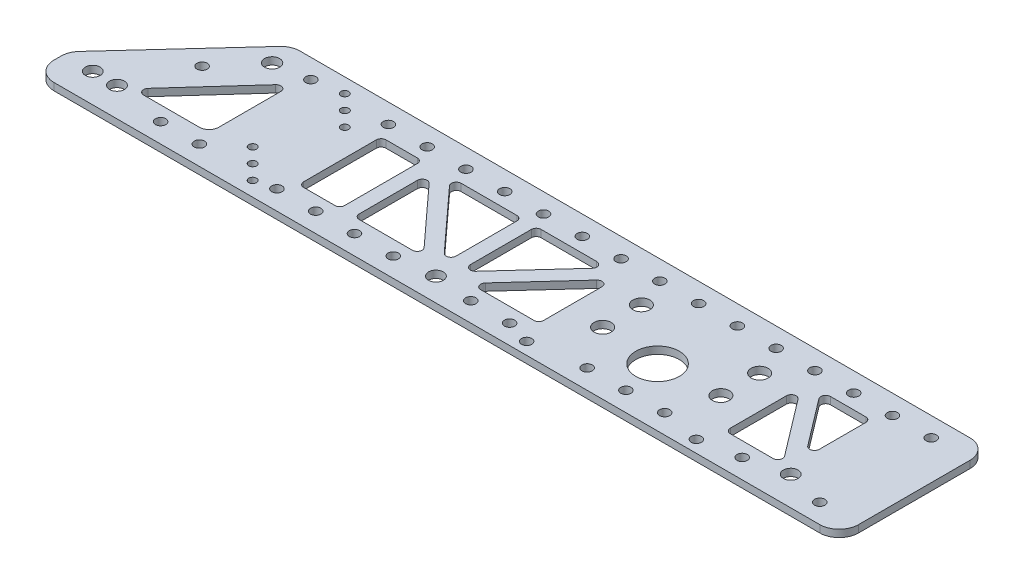
from build123d import *

# Parameters (mm, degrees)
SKETCH1_R           = 4.826
SKETCH1_R_2         = 14.28115
SKETCH1_R_3         = 3.3528
SKETCH1_R_4         = 4.953
SKETCH1_R_5         = 3.3782
SKETCH1_R_6         = 2.5527
SKETCH1_R_7         = 5.5626
BOSS_EXTRUDE1_DEPTH = 4.7625


with BuildPart() as part:
    # Sketch1 → Boss-Extrude1 (new body)
    with BuildSketch(Plane.XZ):
        with BuildLine():
            Line((3.338142419, -25.866609912), (66.074894217, -94.306702782))
            ThreePointArc((66.074894217, -94.306702782), (70.322928635, -97.34992205), (75.436751798, -98.425))
            Line((75.436751798, -98.425), (514.35, -98.425))
            ThreePointArc((514.35, -98.425), (523.330256121, -94.705256121), (527.05, -85.725))
            Line((527.05, -85.725), (527.05, -12.7))
            ThreePointArc((527.05, -12.7), (523.330256121, -3.719743879), (514.35, 0))
            Line((514.35, 0), (12.7, 0))
            ThreePointArc((12.7, 0), (3.719743879, -3.719743879), (0, -12.7))
            Line((0, -12.7), (0, -17.28490713))
            ThreePointArc((0, -17.28490713), (0.863919752, -21.888949307), (3.338142419, -25.866609912))
        make_face()
        with Locations((34.925, -19.05)):
            Circle(SKETCH1_R, mode=Mode.SUBTRACT)
        with Locations((476.25, -19.05)):
            Circle(SKETCH1_R, mode=Mode.SUBTRACT)
        with Locations((19.05, -19.05)):
            Circle(SKETCH1_R, mode=Mode.SUBTRACT)
        with Locations((247.65, -15.24)):
            Circle(SKETCH1_R, mode=Mode.SUBTRACT)
        with Locations((369.99417663, -38.1)):
            Circle(SKETCH1_R_2, mode=Mode.SUBTRACT)
        with Locations((314.41897663, -7.9248)):
            Circle(SKETCH1_R_3, mode=Mode.SUBTRACT)
        with Locations((425.56937663, -7.9248)):
            Circle(SKETCH1_R_3, mode=Mode.SUBTRACT)
        with Locations((73.025, -82.55)):
            Circle(SKETCH1_R_4, mode=Mode.SUBTRACT)
        with Locations((95.25, -12.7)):
            Circle(SKETCH1_R_5, mode=Mode.SUBTRACT)
        with Locations((95.25, -85.725)):
            Circle(SKETCH1_R_5, mode=Mode.SUBTRACT)
        with Locations((146.05, -12.7)):
            Circle(SKETCH1_R_5, mode=Mode.SUBTRACT)
        with Locations((146.05, -85.725)):
            Circle(SKETCH1_R_5, mode=Mode.SUBTRACT)
        with Locations((171.45, -12.7)):
            Circle(SKETCH1_R_5, mode=Mode.SUBTRACT)
        with Locations((171.45, -85.725)):
            Circle(SKETCH1_R_5, mode=Mode.SUBTRACT)
        with Locations((196.85, -12.7)):
            Circle(SKETCH1_R_5, mode=Mode.SUBTRACT)
        with Locations((196.85, -85.725)):
            Circle(SKETCH1_R_5, mode=Mode.SUBTRACT)
        with Locations((222.25, -12.7)):
            Circle(SKETCH1_R_5, mode=Mode.SUBTRACT)
        with Locations((222.25, -85.725)):
            Circle(SKETCH1_R_5, mode=Mode.SUBTRACT)
        with Locations((247.65, -85.725)):
            Circle(SKETCH1_R_5, mode=Mode.SUBTRACT)
        with Locations((273.05, -12.7)):
            Circle(SKETCH1_R_5, mode=Mode.SUBTRACT)
        with Locations((273.05, -85.725)):
            Circle(SKETCH1_R_5, mode=Mode.SUBTRACT)
        with Locations((298.45, -12.7)):
            Circle(SKETCH1_R_5, mode=Mode.SUBTRACT)
        with Locations((298.45, -85.725)):
            Circle(SKETCH1_R_5, mode=Mode.SUBTRACT)
        with Locations((323.85, -85.725)):
            Circle(SKETCH1_R_5, mode=Mode.SUBTRACT)
        with Locations((349.25, -12.7)):
            Circle(SKETCH1_R_5, mode=Mode.SUBTRACT)
        with Locations((349.25, -85.725)):
            Circle(SKETCH1_R_5, mode=Mode.SUBTRACT)
        with Locations((374.65, -12.7)):
            Circle(SKETCH1_R_5, mode=Mode.SUBTRACT)
        with Locations((374.65, -85.725)):
            Circle(SKETCH1_R_5, mode=Mode.SUBTRACT)
        with Locations((400.05, -12.7)):
            Circle(SKETCH1_R_5, mode=Mode.SUBTRACT)
        with Locations((400.05, -85.725)):
            Circle(SKETCH1_R_5, mode=Mode.SUBTRACT)
        with Locations((425.45, -85.725)):
            Circle(SKETCH1_R_5, mode=Mode.SUBTRACT)
        with Locations((450.85, -12.7)):
            Circle(SKETCH1_R_5, mode=Mode.SUBTRACT)
        with Locations((450.85, -85.725)):
            Circle(SKETCH1_R_5, mode=Mode.SUBTRACT)
        with Locations((476.25, -85.725)):
            Circle(SKETCH1_R_5, mode=Mode.SUBTRACT)
        with Locations((501.65, -12.7)):
            Circle(SKETCH1_R_5, mode=Mode.SUBTRACT)
        with Locations((501.65, -85.725)):
            Circle(SKETCH1_R_5, mode=Mode.SUBTRACT)
        with Locations((123.825, -19.05)):
            Circle(SKETCH1_R_6, mode=Mode.SUBTRACT)
        with Locations((114.3, -28.575)):
            Circle(SKETCH1_R_6, mode=Mode.SUBTRACT)
        with Locations((133.35, -9.525)):
            Circle(SKETCH1_R_6, mode=Mode.SUBTRACT)
        with Locations((114.3, -88.9)):
            Circle(SKETCH1_R_6, mode=Mode.SUBTRACT)
        with Locations((123.825, -79.375)):
            Circle(SKETCH1_R_6, mode=Mode.SUBTRACT)
        with Locations((133.35, -69.85)):
            Circle(SKETCH1_R_6, mode=Mode.SUBTRACT)
        with Locations((331.25917663, -40.8178)):
            Circle(SKETCH1_R_7, mode=Mode.SUBTRACT)
        with Locations((408.72917663, -66.2178)):
            Circle(SKETCH1_R_7, mode=Mode.SUBTRACT)
        with Locations((331.25917663, -66.2178)):
            Circle(SKETCH1_R_7, mode=Mode.SUBTRACT)
        with Locations((408.72917663, -40.8178)):
            Circle(SKETCH1_R_7, mode=Mode.SUBTRACT)
        with Locations((69.85, -12.7)):
            Circle(SKETCH1_R_5, mode=Mode.SUBTRACT)
        with Locations((51.950539741, -57.756517342)):
            Circle(SKETCH1_R_5, mode=Mode.SUBTRACT)
        with BuildLine():
            Line((49.23354708, -22.225), (85.725, -22.225))
            ThreePointArc((85.725, -22.225), (90.215128061, -24.084871939), (92.075, -28.575))
            Line((92.075, -28.575), (92.075, -69.241869017))
            ThreePointArc((92.075, -69.241869017), (90.041376556, -72.204618509), (86.545623901, -71.37201882))
            Line((86.545623901, -71.37201882), (46.879170981, -27.530149804))
            ThreePointArc((46.879170981, -27.530149804), (46.33149172, -24.112094846), (49.23354708, -22.225))
        make_face(mode=Mode.SUBTRACT)
        with BuildLine():
            Line((174.53102337, -76.2), (153.9875, -76.2))
            ThreePointArc((153.9875, -76.2), (151.74243597, -75.27006403), (150.8125, -73.025))
            Line((150.8125, -73.025), (150.8125, -25.4))
            ThreePointArc((150.8125, -25.4), (151.74243597, -23.15493597), (153.9875, -22.225))
            Line((153.9875, -22.225), (174.53102337, -22.225))
            ThreePointArc((174.53102337, -22.225), (176.7760874, -23.15493597), (177.70602337, -25.4))
            Line((177.70602337, -25.4), (177.70602337, -73.025))
            ThreePointArc((177.70602337, -73.025), (176.7760874, -75.27006403), (174.53102337, -76.2))
        make_face(mode=Mode.SUBTRACT)
        with BuildLine():
            Line((227.625953961, -27.542449226), (192.749212716, -65.68702112))
            ThreePointArc((192.749212716, -65.68702112), (189.25689352, -66.504322828), (187.23102337, -63.544571894))
            Line((187.23102337, -63.544571894), (187.23102337, -25.4))
            ThreePointArc((187.23102337, -25.4), (188.16095934, -23.15493597), (190.40602337, -22.225))
            Line((190.40602337, -22.225), (225.282764614, -22.225))
            ThreePointArc((225.282764614, -22.225), (228.188182079, -24.119697554), (227.625953961, -27.542449226))
        make_face(mode=Mode.SUBTRACT)
        with BuildLine():
            Line((252.4125, -73.025), (252.4125, -33.144184818))
            ThreePointArc((252.4125, -33.144184818), (254.43837015, -30.184433885), (257.930689347, -31.001735592))
            Line((257.930689347, -31.001735592), (294.394930591, -70.882550774))
            ThreePointArc((294.394930591, -70.882550774), (294.957158709, -74.305302446), (292.051741244, -76.2))
            Line((292.051741244, -76.2), (255.5875, -76.2))
            ThreePointArc((255.5875, -76.2), (253.34243597, -75.27006403), (252.4125, -73.025))
        make_face(mode=Mode.SUBTRACT)
        with BuildLine():
            Line((239.7125, -76.2), (203.248258756, -76.2))
            ThreePointArc((203.248258756, -76.2), (200.342841291, -74.305302446), (200.905069409, -70.882550774))
            Line((200.905069409, -70.882550774), (237.369310653, -31.001735592))
            ThreePointArc((237.369310653, -31.001735592), (240.86162985, -30.184433885), (242.8875, -33.144184818))
            Line((242.8875, -33.144184818), (242.8875, -73.025))
            ThreePointArc((242.8875, -73.025), (241.95756403, -75.27006403), (239.7125, -76.2))
        make_face(mode=Mode.SUBTRACT)
        with BuildLine():
            Line((270.017235386, -22.225), (304.89397663, -22.225))
            ThreePointArc((304.89397663, -22.225), (307.13904066, -23.15493597), (308.06897663, -25.4))
            Line((308.06897663, -25.4), (308.06897663, -63.544571894))
            ThreePointArc((308.06897663, -63.544571894), (306.04310648, -66.504322828), (302.550787284, -65.68702112))
            Line((302.550787284, -65.68702112), (267.674046039, -27.542449226))
            ThreePointArc((267.674046039, -27.542449226), (267.111817921, -24.119697554), (270.017235386, -22.225))
        make_face(mode=Mode.SUBTRACT)
        with BuildLine():
            Line((433.50687663, -22.225), (461.453022572, -22.225))
            ThreePointArc((461.453022572, -22.225), (464.297387539, -23.989250932), (463.980698305, -27.321322562))
            Line((463.980698305, -27.321322562), (436.034552363, -64.087036098))
            ThreePointArc((436.034552363, -64.087036098), (432.493157106, -65.174533525), (430.33187663, -62.165713536))
            Line((430.33187663, -62.165713536), (430.33187663, -25.4))
            ThreePointArc((430.33187663, -25.4), (431.2618126, -23.15493597), (433.50687663, -22.225))
        make_face(mode=Mode.SUBTRACT)
        with BuildLine():
            Line((442.665404361, -71.103677438), (465.784824267, -40.687963902))
            ThreePointArc((465.784824267, -40.687963902), (469.326219524, -39.600466475), (471.4875, -42.609286464))
            Line((471.4875, -42.609286464), (471.4875, -73.025))
            ThreePointArc((471.4875, -73.025), (470.55756403, -75.27006403), (468.3125, -76.2))
            Line((468.3125, -76.2), (445.193080094, -76.2))
            ThreePointArc((445.193080094, -76.2), (442.348715126, -74.435749068), (442.665404361, -71.103677438))
        make_face(mode=Mode.SUBTRACT)
    extrude(amount=-BOSS_EXTRUDE1_DEPTH)


solid = part.part
